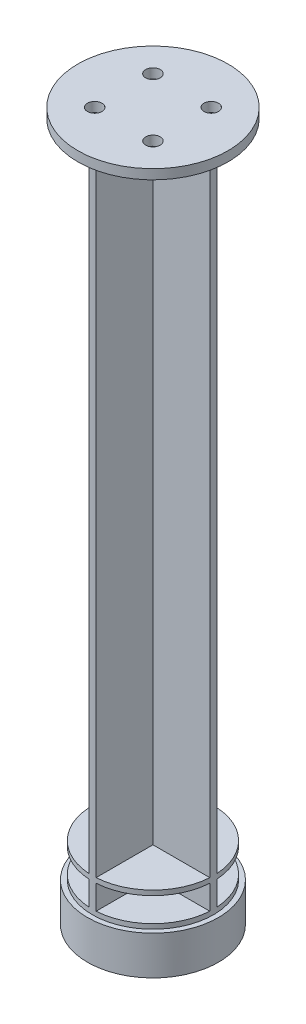
from build123d import *

# Parameters (mm, degrees)
SKETCH1_R           = 13.5
BOSS_EXTRUDE1_DEPTH = 8
SKETCH3_R           = 12.5
BOSS_EXTRUDE3_DEPTH = 1
BOSS_EXTRUDE4_DEPTH = 135
SKETCH5_R           = 12.5
BOSS_EXTRUDE5_DEPTH = 1
SKETCH7_R           = 15.5
BOSS_EXTRUDE8_DEPTH = 2
SKETCH9_R           = 1.5
CUT_EXTRUDE1_DEPTH  = 2


with BuildPart() as part:
    # Sketch1 → Boss-Extrude1 (new body)
    with BuildSketch(Plane(origin=(0, 0, 0), x_dir=(1, 0, 0), z_dir=(0, 1, 0))):
        Circle(SKETCH1_R)
    extrude(amount=BOSS_EXTRUDE1_DEPTH)

    # Sketch3 → Boss-Extrude3 (add)
    with BuildSketch(Plane(origin=(0, 8, 0), x_dir=(1, 0, 0), z_dir=(0, 1, 0))):
        Circle(SKETCH3_R)
    extrude(amount=BOSS_EXTRUDE3_DEPTH)

    # Sketch4 → Boss-Extrude4 (add)
    with BuildSketch(Plane(origin=(0, 9, 0), x_dir=(1, 0, 0), z_dir=(0, 1, 0))):
        with BuildLine():
            Line((-0.75, -0.75), (-12.477479713, -0.75))
            ThreePointArc((-12.477479713, -0.75), (-12.5, 0), (-12.477479713, 0.75))
            Line((-12.477479713, 0.75), (-0.75, 0.75))
            Line((-0.75, 0.75), (-0.75, 12.477479713))
            ThreePointArc((-0.75, 12.477479713), (0, 12.5), (0.75, 12.477479713))
            Line((0.75, 12.477479713), (0.75, 0.75))
            Line((0.75, 0.75), (12.477479713, 0.75))
            ThreePointArc((12.477479713, 0.75), (12.5, 0), (12.477479713, -0.75))
            Line((12.477479713, -0.75), (0.75, -0.75))
            Line((0.75, -0.75), (0.75, -12.477479713))
            ThreePointArc((0.75, -12.477479713), (0, -12.5), (-0.75, -12.477479713))
            Line((-0.75, -12.477479713), (-0.75, -0.75))
        make_face()
    extrude(amount=BOSS_EXTRUDE4_DEPTH)

    # Sketch5 → Boss-Extrude5 (add)
    with BuildSketch(Plane(origin=(0, 14, 0), x_dir=(1, 0, 0), z_dir=(0, 1, 0))):
        Circle(SKETCH5_R)
    extrude(amount=BOSS_EXTRUDE5_DEPTH)

    # Sketch8 → Revolve1 (revolve)
    with BuildSketch(Plane.XY):
        Polygon((0, 0), (0, -7), (13.5, 0), align=None)
    revolve(axis=Axis((0, 0, 0), (0, -1, 0)))

    # Sketch7 → Boss-Extrude8 (add)
    with BuildSketch(Plane(origin=(0, 144, 0), x_dir=(1, 0, 0), z_dir=(0, 1, 0))):
        Circle(SKETCH7_R)
    extrude(amount=BOSS_EXTRUDE8_DEPTH)

    # Sketch9 → Cut-Extrude1 (cut)
    with BuildSketch(Plane(origin=(0, 146, 0), x_dir=(1, 0, 0), z_dir=(0, 1, 0))):
        with Locations((-6.01040764, 6.01040764)):
            Circle(SKETCH9_R)
        with Locations((6.01040764, 6.01040764)):
            Circle(SKETCH9_R)
        with Locations((6.01040764, -6.01040764)):
            Circle(SKETCH9_R)
        with Locations((-6.01040764, -6.01040764)):
            Circle(SKETCH9_R)
    extrude(amount=-CUT_EXTRUDE1_DEPTH, mode=Mode.SUBTRACT)


solid = part.part
